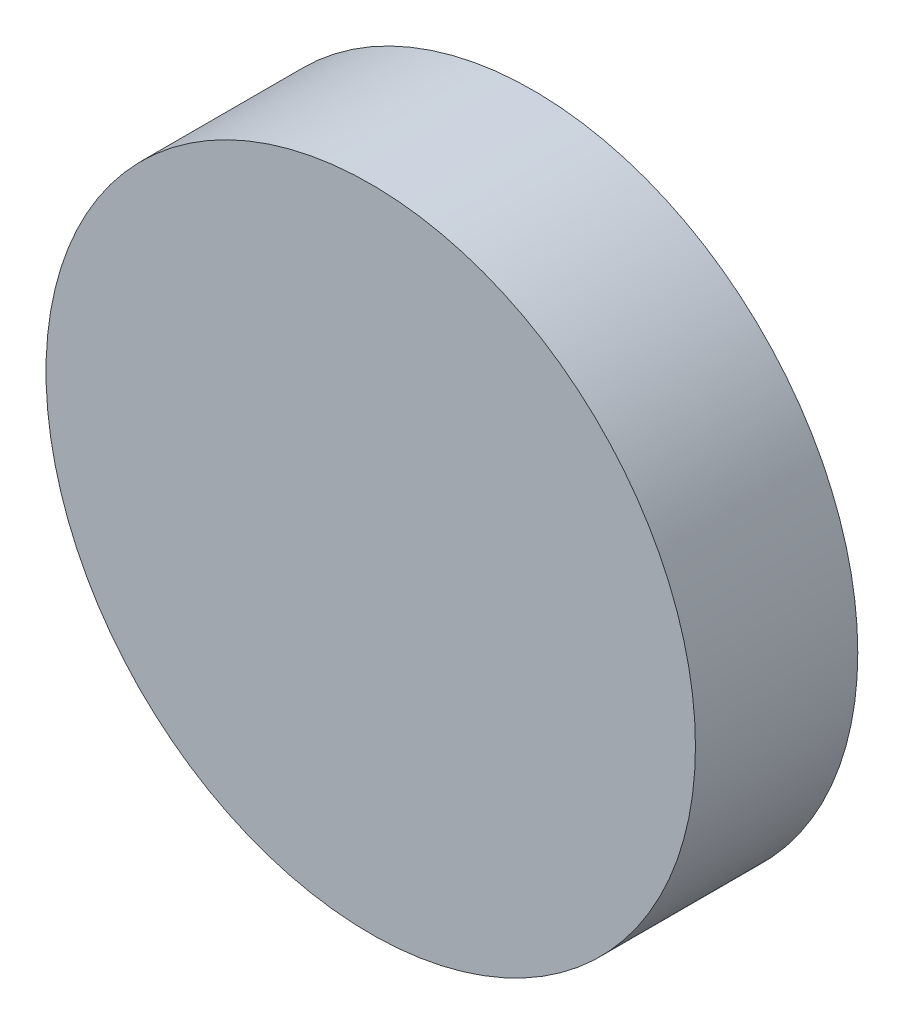
from build123d import *

# Parameters (mm, degrees)
SKETCH1_R           = 10
BOSS_EXTRUDE1_DEPTH = 5
SKETCH1_3_R         = 7.5
CUT_EXTRUDE1_DEPTH  = 3


with BuildPart() as part:
    # Sketch1 → Boss-Extrude1 (new body)
    with BuildSketch(Plane.XY):
        Circle(SKETCH1_R)
    extrude(amount=BOSS_EXTRUDE1_DEPTH)

    # Sketch1_3 → Cut-Extrude1 (cut)
    with BuildSketch(Plane.XY):
        Circle(SKETCH1_3_R)
    extrude(amount=CUT_EXTRUDE1_DEPTH, mode=Mode.SUBTRACT)


solid = part.part
